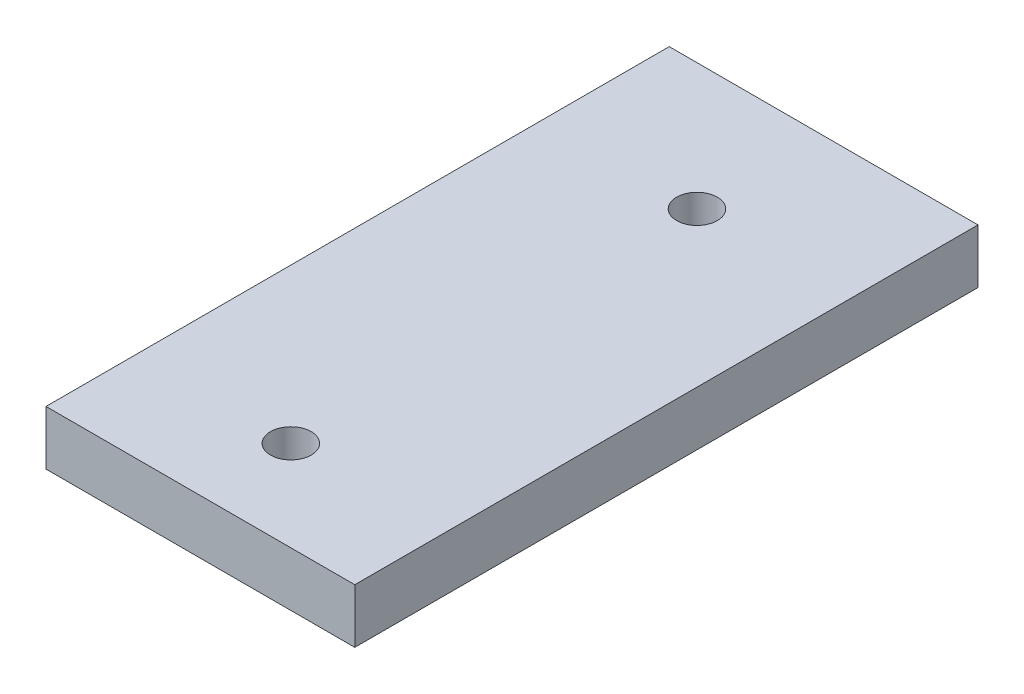
from build123d import *

# Parameters (mm, degrees)
SKETCH1_W           = 34.135361425
SKETCH1_H           = 68.896006058
BOSS_EXTRUDE1_DEPTH = 6
CUT_EXTRUDE1_REACH  = 8
SKETCH2_R           = 2.25


with BuildPart() as part:
    # Sketch1 → Boss-Extrude1 (new body)
    with BuildSketch(Plane(origin=(0, 0, 0), x_dir=(1, 0, 0), z_dir=(0, 1, 0))):
        with Locations((2.281890395, 6.551561836)):
            Rectangle(SKETCH1_W, SKETCH1_H)
    extrude(amount=BOSS_EXTRUDE1_DEPTH)

    # Sketch2 → Cut-Extrude1 (cut, up to next)
    with BuildSketch(Plane(origin=(0, 6, 0), x_dir=(1, 0, 0), z_dir=(0, 1, 0)), mode=Mode.PRIVATE) as cut_extrude1_sk1:
        with Locations((2.281890395, -17.896441193)):
            Circle(SKETCH2_R)
    cut_extrude1_tool1 = extrude(cut_extrude1_sk1.sketch, amount=-CUT_EXTRUDE1_REACH, mode=Mode.PRIVATE) & part.part
    add(cut_extrude1_tool1.solids().sort_by_distance((2.28189, 6, 17.896441))[0], mode=Mode.SUBTRACT)
    # Sketch2 → Cut-Extrude1 (cut, up to next)
    with BuildSketch(Plane(origin=(0, 6, 0), x_dir=(1, 0, 0), z_dir=(0, 1, 0)), mode=Mode.PRIVATE) as cut_extrude1_sk2:
        with Locations((2.281890395, 26.999564865)):
            Circle(SKETCH2_R)
    cut_extrude1_tool2 = extrude(cut_extrude1_sk2.sketch, amount=-CUT_EXTRUDE1_REACH, mode=Mode.PRIVATE) & part.part
    add(cut_extrude1_tool2.solids().sort_by_distance((2.28189, 6, -26.999565))[0], mode=Mode.SUBTRACT)


solid = part.part
